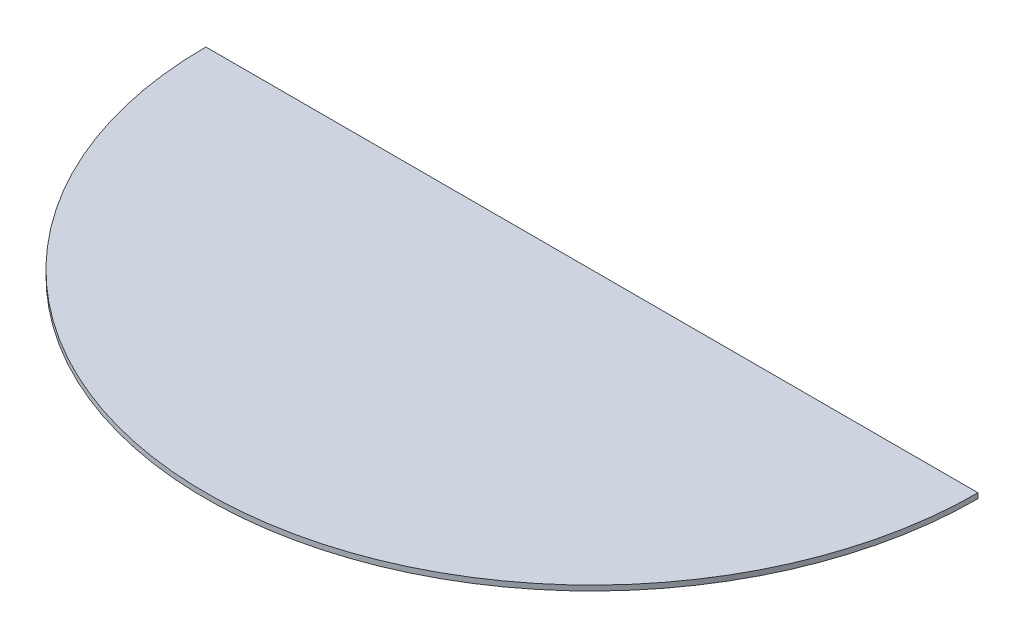
from build123d import *

# Parameters (mm, degrees)
BOSS_EXTRUDE1_DEPTH = 1


with BuildPart() as part:
    # Sketch1 → Boss-Extrude1 (new body)
    with BuildSketch(Plane(origin=(0, 0, 0), x_dir=(1, 0, 0), z_dir=(0, 1, 0))):
        with BuildLine():
            Line((-75, 0), (75, 0))
            ThreePointArc((75, 0), (0, -75), (-75, 0))
        make_face()
    extrude(amount=BOSS_EXTRUDE1_DEPTH)


solid = part.part
